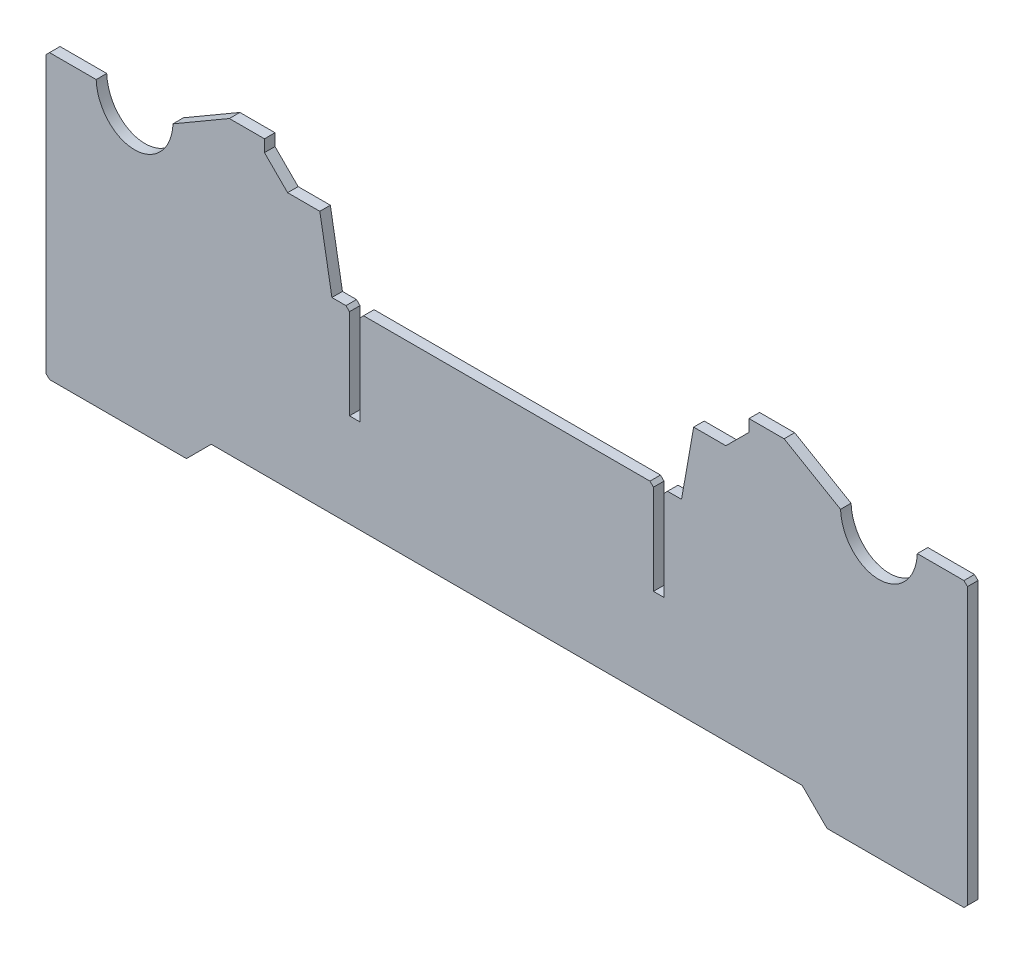
from build123d import *

# Parameters (mm, degrees)
BOSS_EXTRUDE1_DEPTH = 3
SKETCH2_W           = 3
SKETCH2_H           = 4.791544689
CUT_EXTRUDE1_DEPTH  = 15
CHAMFER1_SIZE       = 1
CHAMFER2_SIZE       = 1


with BuildPart() as part:
    # Sketch1 → Boss-Extrude1 (new body)
    with BuildSketch(Plane.XY):
        with BuildLine():
            Line((93.184787819, -119.514382091), (261.489822447, -119.514382091))
            Line((261.489822447, -119.514382091), (268.560890259, -126.585449903))
            Line((268.560890259, -126.585449903), (308.560890259, -126.585449903))
            Line((308.560890259, -126.585449903), (308.560890259, -45.93363109))
            Line((308.560890259, -45.93363109), (294.267338786, -45.93363109))
            add(Edge.make_bspline(
                [(272.407878144, -45.934404782), (272.465337406, -47.438364471), (273.073186229, -50.465203155), (275.397677042, -54.367125899), (278.960411882, -57.115608226), (283.338040094, -58.12903526), (287.715596557, -57.115298346), (291.278136829, -54.366563828), (293.602351427, -50.464476548), (294.209985986, -47.437594843), (294.267338786, -45.93363109)],
                knots=[-1.525660034, -1.525660034, -1.525660034, -1.525660034, -1.144245025, -0.762830017, -0.381415008, 0, 0.381415008, 0.762830017, 1.144245025, 1.525660034, 1.525660034, 1.525660034, 1.525660034], degree=3))
            Line((272.407878144, -45.934404782), (256.337305133, -36.585449903))
            Line((256.337305133, -36.585449903), (246.337305133, -36.585449903))
            Line((246.337305133, -36.585449903), (246.337305133, -39.999663466))
            Line((246.337305133, -39.999663466), (239.751518696, -46.585449903))
            Line((239.751518696, -46.585449903), (230.574035326, -46.585449903))
            Line((230.574035326, -46.585449903), (227.127859803, -66.129682494))
            Line((227.127859803, -66.129682494), (127.546750463, -66.129682494))
            Line((127.546750463, -66.129682494), (124.10057494, -46.585449903))
            Line((124.10057494, -46.585449903), (114.923091571, -46.585449903))
            Line((114.923091571, -46.585449903), (108.337305133, -39.999663466))
            Line((108.337305133, -39.999663466), (108.337305133, -36.585449903))
            Line((108.337305133, -36.585449903), (98.337305133, -36.585449903))
            Line((98.337305133, -36.585449903), (82.267030577, -45.934761617))
            add(Edge.make_bspline(
                [(60.407579689, -45.934761617), (60.464998848, -47.438718586), (61.072758356, -50.465565598), (63.397111959, -54.367547882), (66.959733327, -57.116142381), (71.337305133, -58.129720884), (75.714876939, -57.116142381), (79.277498308, -54.367547882), (81.60185191, -50.465565598), (82.209611419, -47.438718586), (82.267030577, -45.934761617)],
                knots=[1.615943427, 1.615943427, 1.615943427, 1.615943427, 1.997355734, 2.37876804, 2.760180347, 3.141592654, 3.52300496, 3.904417267, 4.285829573, 4.66724188, 4.66724188, 4.66724188, 4.66724188], degree=3))
            Line((60.407579689, -45.934761617), (46.113720007, -45.934761617))
            Line((46.113720007, -45.934761617), (46.113720007, -126.585449903))
            Line((46.113720007, -126.585449903), (86.113720007, -126.585449903))
            Line((86.113720007, -126.585449903), (93.184787819, -119.514382091))
        make_face()
    extrude(amount=BOSS_EXTRUDE1_DEPTH)

    # Sketch2 → Cut-Extrude1 (cut)
    with BuildSketch(Plane(origin=(0, 0, 0), x_dir=(-1, 0, 0), z_dir=(0, 0, -1))):
        Polygon((-222.127859803, -66.129682494), (-222.127859803, -71.338137805), (-222.127859803, -92.822032293), (-219.127859803, -92.822032293), (-219.127859803, -71.338137805), (-219.127859803, -66.129682494), align=None)
        with Locations((-220.627859803, -63.73391015)):
            Rectangle(SKETCH2_W, SKETCH2_H)
        with Locations((-134.046750463, -63.73391015)):
            Rectangle(SKETCH2_W, SKETCH2_H)
        Polygon((-132.546750463, -66.129682494), (-135.546750463, -66.129682494), (-135.546750463, -71.338137805), (-135.546750463, -92.822032293), (-132.546750463, -92.822032293), (-132.546750463, -71.338137805), align=None)
    extrude(amount=-CUT_EXTRUDE1_DEPTH, mode=Mode.SUBTRACT)

    # Chamfer1
    chamfer1_edges = [part.edges().sort_by_distance(p)[0] for p in [
        (222.127859803, -66.129682494, 1.5),
        (219.127859803, -66.129682494, 1.5),
        (132.546750463, -66.129682494, 1.5),
        (135.546750463, -66.129682494, 1.5),
    ]]
    chamfer(chamfer1_edges, length=CHAMFER1_SIZE)

    # Chamfer2
    chamfer2_edges = [part.edges().sort_by_distance(p)[0] for p in [
        (308.560890259, -45.93363109, 1.5),
        (308.560890259, -126.585449903, 1.5),
        (46.113720007, -126.585449903, 1.5),
        (46.113720007, -45.934761617, 1.5),
    ]]
    chamfer(chamfer2_edges, length=CHAMFER2_SIZE)


solid = part.part
